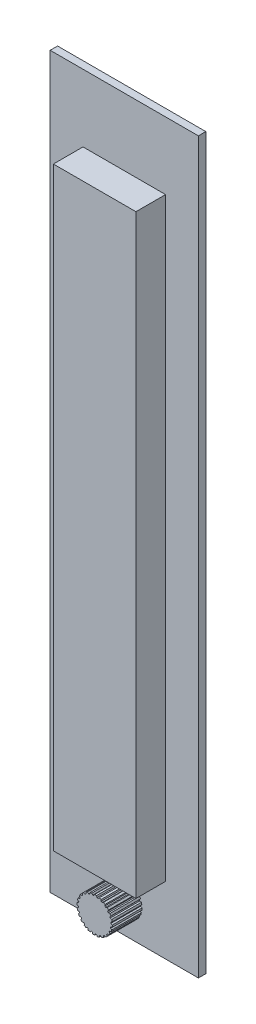
from build123d import *

# Parameters (mm, degrees)
SKETCH1_W           = 50.8
SKETCH1_H           = 250
SKETCH1_R           = 5.573606459
SKETCH1_W_2         = 28.29928572
SKETCH1_H_2         = 203.881879194
BOSS_EXTRUDE1_DEPTH = 2.54
SKETCH1_2_W         = 28.29928572
SKETCH1_2_H         = 203.881879194
BOSS_EXTRUDE2_DEPTH = 12.7
SKETCH1_3_R         = 5.573606459
BOSS_EXTRUDE3_DEPTH = 12.7
BOSS_EXTRUDE4_DEPTH = 10.16
CIRPATTERN1_COUNT   = 24


with BuildPart() as part:
    # Sketch1 → Boss-Extrude1 (new body)
    with BuildSketch(Plane.XY):
        Rectangle(SKETCH1_W, SKETCH1_H)
        with Locations((0, -113.873825503)):
            Circle(SKETCH1_R, mode=Mode.SUBTRACT)
        Rectangle(SKETCH1_W_2, SKETCH1_H_2, mode=Mode.SUBTRACT)
    extrude(amount=BOSS_EXTRUDE1_DEPTH)

    # Sketch1_2 → Boss-Extrude2 (add)
    with BuildSketch(Plane.XY):
        Rectangle(SKETCH1_2_W, SKETCH1_2_H)
    extrude(amount=BOSS_EXTRUDE2_DEPTH)

    # Sketch1_3 → Boss-Extrude3 (add)
    with BuildSketch(Plane.XY):
        with Locations((0, -113.873825503)):
            Circle(SKETCH1_3_R)
    extrude(amount=BOSS_EXTRUDE3_DEPTH)

    # Sketch2 → Boss-Extrude4 (add)
    with BuildSketch(Plane.XY.offset(12.7)):
        Polygon((-0.665542468, -109.111248143), (0, -107.823249371), (0.659256269, -107.823249371), (1.06965096, -109.111248143), align=None)
    boss_extrude4 = extrude(amount=-BOSS_EXTRUDE4_DEPTH)

    # CirPattern1: Boss-Extrude4 ×24 about axis
    cirpattern1_axis = Axis((0, -113.873825503, 12.7), (0, 0, -1))
    for i in range(1, CIRPATTERN1_COUNT):
        add(boss_extrude4.rotate(cirpattern1_axis, i * 360 / CIRPATTERN1_COUNT))


solid = part.part
